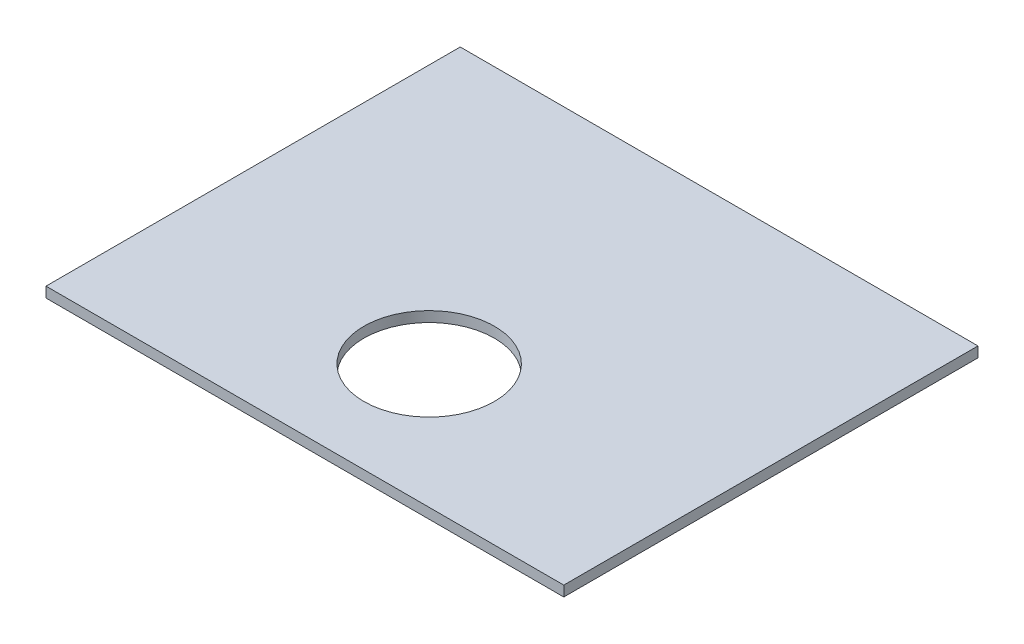
from build123d import *

# Parameters (mm, degrees)
SKETCH1_W           = 500
SKETCH1_H           = 400
BOSS_EXTRUDE1_DEPTH = 10
SKETCH2_R           = 63
CUT_EXTRUDE1_DEPTH  = 20


with BuildPart() as part:
    # Sketch1 → Boss-Extrude1 (new body)
    with BuildSketch(Plane(origin=(0, 0, 0), x_dir=(1, 0, 0), z_dir=(0, 1, 0))):
        Rectangle(SKETCH1_W, SKETCH1_H)
    extrude(amount=-BOSS_EXTRUDE1_DEPTH)

    # Sketch2 → Cut-Extrude1 (cut)
    with BuildSketch(Plane(origin=(0, 0, 0), x_dir=(1, 0, 0), z_dir=(0, 1, 0))):
        with Locations((0, -80)):
            Circle(SKETCH2_R)
    extrude(amount=-CUT_EXTRUDE1_DEPTH, mode=Mode.SUBTRACT)


solid = part.part
